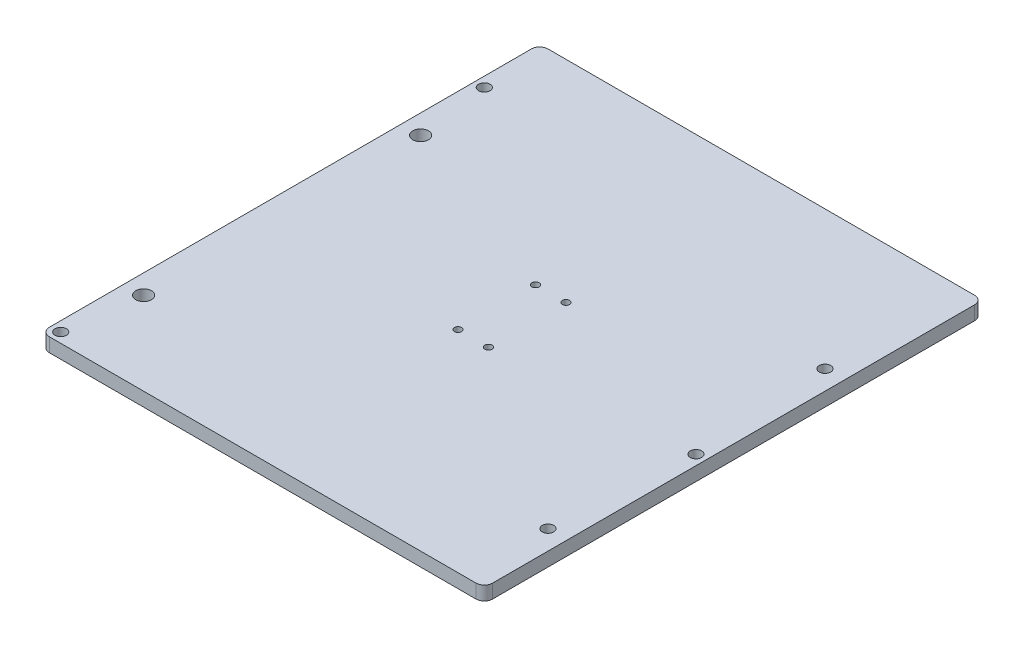
from build123d import *

# Parameters (mm, degrees)
BOSS_EXTRUDE1_DEPTH     = 6.35
WHEEL_HOLES_REACH       = 8.35
SKETCH2_R               = 3.6
SKETCH2_R_2             = 2.625
BUILD_PLATE_HOLES_REACH = 8.35
SKETCH3_R               = 2.625
FILLET1_R               = 3.81
BELT_CLAMP_HOLES_REACH  = 8.35
SKETCH4_R               = 1.65


with BuildPart() as part:
    # Sketch1 → Boss-Extrude1 (new body)
    with BuildSketch(Plane(origin=(0, 0, 0), x_dir=(1, 0, 0), z_dir=(0, 1, 0))):
        Polygon((0, 0), (0, 203.2), (203.2, 203.2), (203.2, 0), (203.2, -25.4), (0, -25.4), align=None)
    extrude(amount=BOSS_EXTRUDE1_DEPTH)

    # Sketch2 → wheel holes (cut, up to next)
    with BuildSketch(Plane(origin=(0, 6.35, 0), x_dir=(1, 0, 0), z_dir=(0, 1, 0)), mode=Mode.PRIVATE) as wheel_holes_sk1:
        with Locations((8.90143, 12.7)):
            Circle(SKETCH2_R)
    wheel_holes_tool1 = extrude(wheel_holes_sk1.sketch, amount=-WHEEL_HOLES_REACH, mode=Mode.PRIVATE) & part.part
    add(wheel_holes_tool1.solids().sort_by_distance((8.90143, 6.35, -12.7))[0], mode=Mode.SUBTRACT)
    # Sketch2 → wheel holes (cut, up to next)
    with BuildSketch(Plane(origin=(0, 6.35, 0), x_dir=(1, 0, 0), z_dir=(0, 1, 0)), mode=Mode.PRIVATE) as wheel_holes_sk2:
        with Locations((8.90143, 139.7)):
            Circle(SKETCH2_R)
    wheel_holes_tool2 = extrude(wheel_holes_sk2.sketch, amount=-WHEEL_HOLES_REACH, mode=Mode.PRIVATE) & part.part
    add(wheel_holes_tool2.solids().sort_by_distance((8.90143, 6.35, -139.7))[0], mode=Mode.SUBTRACT)
    # Sketch2 → wheel holes (cut, up to next)
    with BuildSketch(Plane(origin=(0, 6.35, 0), x_dir=(1, 0, 0), z_dir=(0, 1, 0)), mode=Mode.PRIVATE) as wheel_holes_sk3:
        with Locations((194.29857, 12.7)):
            Circle(SKETCH2_R_2)
    wheel_holes_tool3 = extrude(wheel_holes_sk3.sketch, amount=-WHEEL_HOLES_REACH, mode=Mode.PRIVATE) & part.part
    add(wheel_holes_tool3.solids().sort_by_distance((194.29857, 6.35, -12.7))[0], mode=Mode.SUBTRACT)
    # Sketch2 → wheel holes (cut, up to next)
    with BuildSketch(Plane(origin=(0, 6.35, 0), x_dir=(1, 0, 0), z_dir=(0, 1, 0)), mode=Mode.PRIVATE) as wheel_holes_sk4:
        with Locations((194.29857, 139.7)):
            Circle(SKETCH2_R_2)
    wheel_holes_tool4 = extrude(wheel_holes_sk4.sketch, amount=-WHEEL_HOLES_REACH, mode=Mode.PRIVATE) & part.part
    add(wheel_holes_tool4.solids().sort_by_distance((194.29857, 6.35, -139.7))[0], mode=Mode.SUBTRACT)

    # Sketch3 → build plate holes (cut, up to next)
    with BuildSketch(Plane.XZ, mode=Mode.PRIVATE) as build_plate_holes_sk1:
        with Locations((4.50088, 20.90166)):
            Circle(SKETCH3_R)
    build_plate_holes_tool1 = extrude(build_plate_holes_sk1.sketch, amount=-BUILD_PLATE_HOLES_REACH, mode=Mode.PRIVATE) & part.part
    add(build_plate_holes_tool1.solids().sort_by_distance((4.50088, 0, 20.90166))[0], mode=Mode.SUBTRACT)
    # Sketch3 → build plate holes (cut, up to next)
    with BuildSketch(Plane.XZ, mode=Mode.PRIVATE) as build_plate_holes_sk2:
        with Locations((4.50088, -173.29912)):
            Circle(SKETCH3_R)
    build_plate_holes_tool2 = extrude(build_plate_holes_sk2.sketch, amount=-BUILD_PLATE_HOLES_REACH, mode=Mode.PRIVATE) & part.part
    add(build_plate_holes_tool2.solids().sort_by_distance((4.50088, 0, -173.29912))[0], mode=Mode.SUBTRACT)
    # Sketch3 → build plate holes (cut, up to next)
    with BuildSketch(Plane.XZ, mode=Mode.PRIVATE) as build_plate_holes_sk3:
        with Locations((198.6499964, -76.2)):
            Circle(SKETCH3_R)
    build_plate_holes_tool3 = extrude(build_plate_holes_sk3.sketch, amount=-BUILD_PLATE_HOLES_REACH, mode=Mode.PRIVATE) & part.part
    add(build_plate_holes_tool3.solids().sort_by_distance((198.649996, 0, -76.2))[0], mode=Mode.SUBTRACT)

    # Fillet1
    fillet1_edges = [part.edges().sort_by_distance(p)[0] for p in [
        (0, 3.175, -203.2),
        (203.2, 3.175, -203.2),
        (203.2, 3.175, 25.4),
        (0, 3.175, 25.4),
    ]]
    fillet(fillet1_edges, radius=FILLET1_R)

    # Sketch4 → belt clamp holes (cut, up to next)
    with BuildSketch(Plane(origin=(0, 6.35, 0), x_dir=(1, 0, 0), z_dir=(0, 1, 0)), mode=Mode.PRIVATE) as belt_clamp_holes_sk1:
        with Locations((94.6, 106.68)):
            Circle(SKETCH4_R)
    belt_clamp_holes_tool1 = extrude(belt_clamp_holes_sk1.sketch, amount=-BELT_CLAMP_HOLES_REACH, mode=Mode.PRIVATE) & part.part
    add(belt_clamp_holes_tool1.solids().sort_by_distance((94.6, 6.35, -106.68))[0], mode=Mode.SUBTRACT)
    # Sketch4 → belt clamp holes (cut, up to next)
    with BuildSketch(Plane(origin=(0, 6.35, 0), x_dir=(1, 0, 0), z_dir=(0, 1, 0)), mode=Mode.PRIVATE) as belt_clamp_holes_sk2:
        with Locations((108.6, 106.68)):
            Circle(SKETCH4_R)
    belt_clamp_holes_tool2 = extrude(belt_clamp_holes_sk2.sketch, amount=-BELT_CLAMP_HOLES_REACH, mode=Mode.PRIVATE) & part.part
    add(belt_clamp_holes_tool2.solids().sort_by_distance((108.6, 6.35, -106.68))[0], mode=Mode.SUBTRACT)
    # Sketch4 → belt clamp holes (cut, up to next)
    with BuildSketch(Plane(origin=(0, 6.35, 0), x_dir=(1, 0, 0), z_dir=(0, 1, 0)), mode=Mode.PRIVATE) as belt_clamp_holes_sk3:
        with Locations((108.6, 71.12)):
            Circle(SKETCH4_R)
    belt_clamp_holes_tool3 = extrude(belt_clamp_holes_sk3.sketch, amount=-BELT_CLAMP_HOLES_REACH, mode=Mode.PRIVATE) & part.part
    add(belt_clamp_holes_tool3.solids().sort_by_distance((108.6, 6.35, -71.12))[0], mode=Mode.SUBTRACT)
    # Sketch4 → belt clamp holes (cut, up to next)
    with BuildSketch(Plane(origin=(0, 6.35, 0), x_dir=(1, 0, 0), z_dir=(0, 1, 0)), mode=Mode.PRIVATE) as belt_clamp_holes_sk4:
        with Locations((94.6, 71.12)):
            Circle(SKETCH4_R)
    belt_clamp_holes_tool4 = extrude(belt_clamp_holes_sk4.sketch, amount=-BELT_CLAMP_HOLES_REACH, mode=Mode.PRIVATE) & part.part
    add(belt_clamp_holes_tool4.solids().sort_by_distance((94.6, 6.35, -71.12))[0], mode=Mode.SUBTRACT)


solid = part.part
